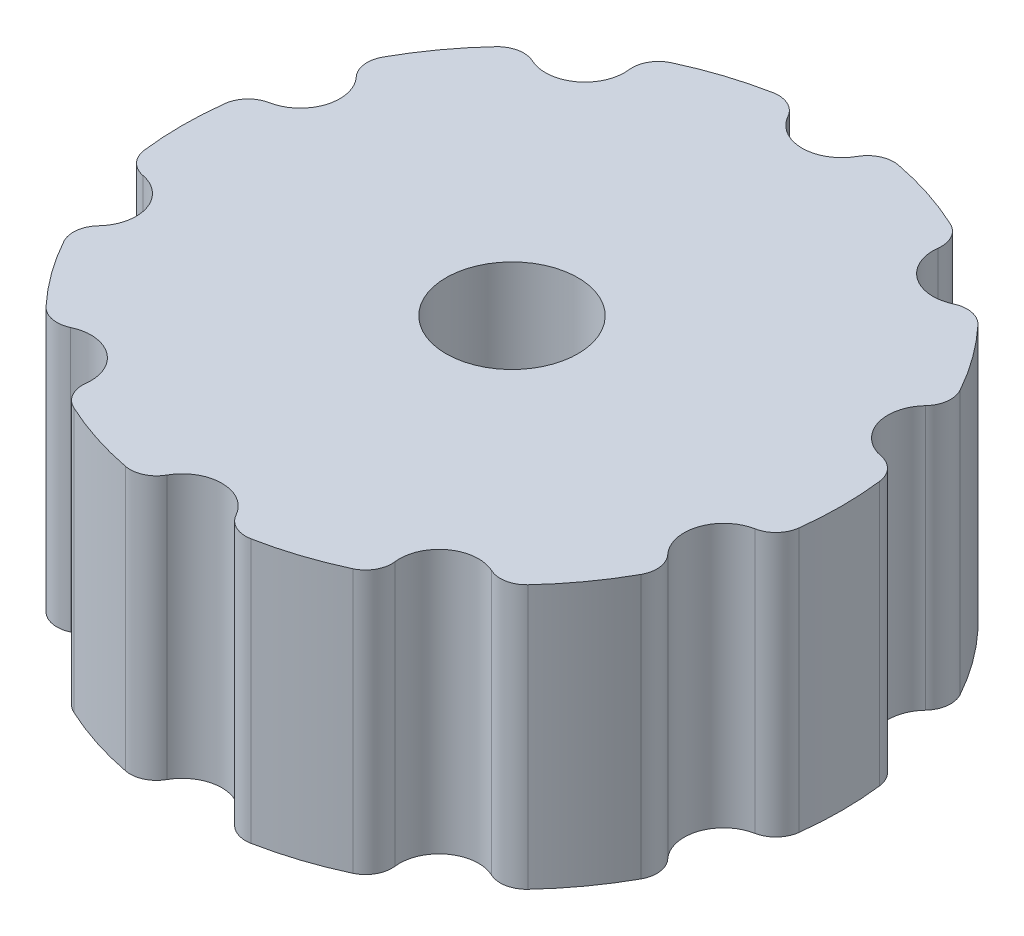
from build123d import *

# Parameters (mm, degrees)
ESQUISSE1_R                        = 12.5
BOSS_EXTRU_1_DEPTH                 = 10
ESQUISSE3_R                        = 1.5
ENL_V_MAT_EXTRU_1_DEPTH            = 10
CONG_1_R                           = 1
R_P_TITION_CIRCULAIRE1_COUNT       = 10
CONG_1_OF_R_P_TITION_CIRCULAIRE1_R = 1
ESQUISSE4_R                        = 2.5
ENL_V_MAT_EXTRU_2_DEPTH            = 10


with BuildPart() as part:
    # Esquisse1 → Boss.-Extru.1 (new body)
    with BuildSketch(Plane(origin=(0, 0, 0), x_dir=(1, 0, 0), z_dir=(0, 1, 0))):
        Circle(ESQUISSE1_R)
    extrude(amount=BOSS_EXTRU_1_DEPTH)

    # Esquisse3 → Enlèv. mat.-Extru.1 (cut)
    with BuildSketch(Plane(origin=(0, 0, 0), x_dir=(-1, 0, 0), z_dir=(0, -1, 0))):
        with Locations((0, -12.5)):
            Circle(ESQUISSE3_R)
    enl_v_mat_extru_1 = extrude(amount=-ENL_V_MAT_EXTRU_1_DEPTH, mode=Mode.SUBTRACT)

    # Congé1
    cong_1_edges = [part.edges().sort_by_distance(p)[0] for p in [
        (-1.497297566, 5, 12.41),
        (1.497297566, 5, 12.41),
    ]]
    fillet(cong_1_edges, radius=CONG_1_R)

    # Répétition circulaire1: Enlèv. mat.-Extru.1 ×10 about axis
    r_p_tition_circulaire1_axis = Axis((0, 0, 0), (0, 1, 0))
    for i in range(1, R_P_TITION_CIRCULAIRE1_COUNT):
        add(enl_v_mat_extru_1.rotate(r_p_tition_circulaire1_axis, i * 360 / R_P_TITION_CIRCULAIRE1_COUNT), mode=Mode.SUBTRACT)

    # Congé1 of Répétition circulaire1
    cong_1_of_r_p_tition_circulaire1_edges = [part.edges().sort_by_distance(p)[0] for p in [
        (6.083075805, 5, 10.919990328),
        (8.505754157, 5, 9.159811473),
        (11.339920974, 5, 5.258915507),
        (12.265301761, 5, 2.410886294),
        (12.265301761, 5, -2.410886294),
        (11.339920974, 5, -5.258915507),
        (8.505754157, 5, -9.159811473),
        (6.083075805, 5, -10.919990328),
        (1.497297566, 5, -12.41),
        (-1.497297566, 5, -12.41),
        (-6.083075805, 5, -10.919990328),
        (-8.505754157, 5, -9.159811473),
        (-11.339920974, 5, -5.258915507),
        (-12.265301761, 5, -2.410886294),
        (-12.265301761, 5, 2.410886294),
        (-11.339920974, 5, 5.258915507),
        (-8.505754157, 5, 9.159811473),
        (-6.083075805, 5, 10.919990328),
    ]]
    fillet(cong_1_of_r_p_tition_circulaire1_edges, radius=CONG_1_OF_R_P_TITION_CIRCULAIRE1_R)

    # Esquisse4 → Enlèv. mat.-Extru.2 (cut)
    with BuildSketch(Plane(origin=(0, 10, 0), x_dir=(1, 0, 0), z_dir=(0, 1, 0))):
        Circle(ESQUISSE4_R)
    extrude(amount=-ENL_V_MAT_EXTRU_2_DEPTH, mode=Mode.SUBTRACT)


solid = part.part
